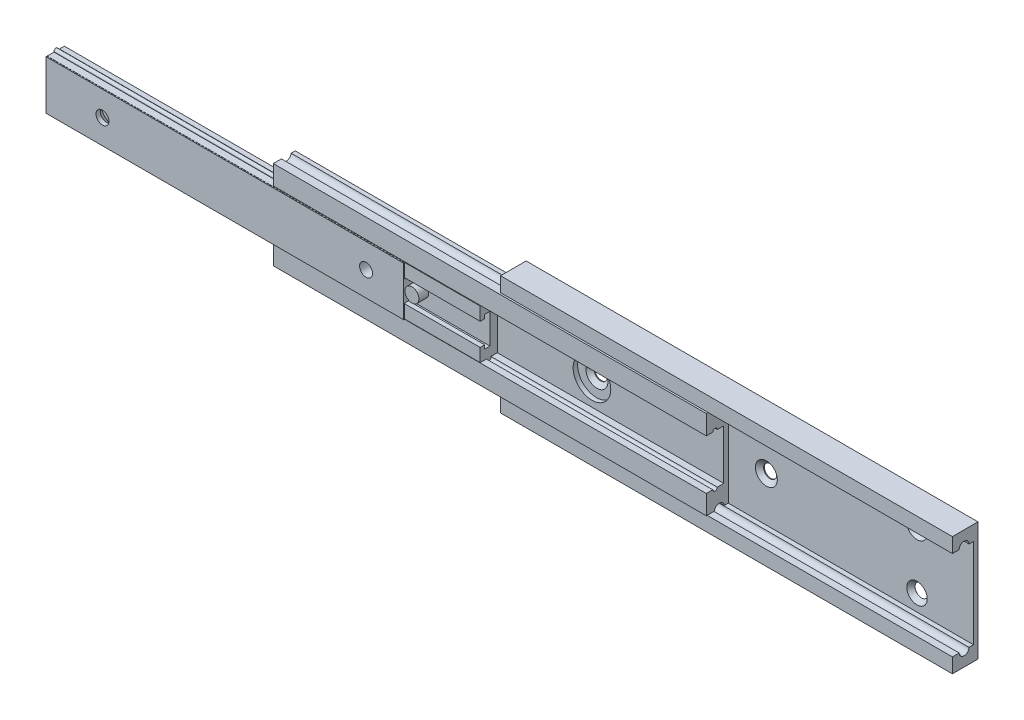
from build123d import *

# Parameters (mm, degrees)
EXTRUDE1_DEPTH        = 152.4
EXTRUDE2_DEPTH        = 146.05
EXTRUDE3_DEPTH        = 146.05
SKETCH9_R             = 2.3749
EXTRUDE4_DEPTH        = 3.302
EXTRUDE5_DEPTH        = 120.65
SKETCH4_R             = 2.1844
CUT_EXTRUDE1_DEPTH    = 1.524
CHAMFER1_SIZE         = 1.27
CHAMFER1_SIZE2        = 1.513527063
CHAMFER1_PART_2_SIZE  = 1.27
CHAMFER1_PART_2_SIZE2 = 1.513527063
CHAMFER1_PART_3_SIZE  = 1.27
CHAMFER1_PART_3_SIZE2 = 1.513527063
SKETCH5_R             = 6.35
CUT_EXTRUDE2_DEPTH    = 1.524
SKETCH6_R             = 2.1844
CUT_EXTRUDE3_DEPTH    = 3.429
CHAMFER2_SIZE         = 1.6637
CHAMFER2_SIZE2        = 1.982720452


with BuildPart() as part:
    # Sketch1 → Extrude1 (new body)
    with BuildSketch(Plane(origin=(0, 0, 0), x_dir=(0, 0, -1), z_dir=(1, 0, 0))):
        with BuildLine():
            Line((-4.318, 20.0421875), (4.318, 20.0421875))
            Line((4.318, 20.0421875), (4.318, -20.0421875))
            Line((4.318, -20.0421875), (-4.318, -20.0421875))
            Line((-4.318, -20.0421875), (-4.318, -15.0891875))
            Line((-4.318, -15.0891875), (-2.032, -15.0891875))
            ThreePointArc((-2.032, -15.0891875), (-0.381, -16.7401875), (1.27, -15.0891875))
            Line((1.27, -15.0891875), (2.794, -15.0891875))
            Line((2.794, -15.0891875), (2.794, 15.0891875))
            Line((2.794, 15.0891875), (1.27, 15.0891875))
            ThreePointArc((1.27, 15.0891875), (-0.381, 16.7401875), (-2.032, 15.0891875))
            Line((-2.032, 15.0891875), (-4.318, 15.0891875))
            Line((-4.318, 15.0891875), (-4.318, 20.0421875))
        make_face()
    extrude(amount=EXTRUDE1_DEPTH)

    # Sketch4 → Cut-Extrude1 (cut)
    with BuildSketch(Plane.XY.offset(-2.794)):
        with Locations((133.35, 9.525)):
            Circle(SKETCH4_R)
        with Locations((133.35, -9.525)):
            Circle(SKETCH4_R)
        with Locations((82.55, 0)):
            Circle(SKETCH4_R)
        with Locations((25.4, 0)):
            Circle(SKETCH4_R)
    extrude(amount=-CUT_EXTRUDE1_DEPTH, mode=Mode.SUBTRACT)

    # Chamfer1
    chamfer1_edges = [part.edges().sort_by_distance(p)[0] for p in [
        (131.1656, 9.525, -2.794),
        (131.1656, -9.525, -2.794),
    ]]
    chamfer1_side = [part.faces().sort_by_distance(p)[0] for p in [
        (75.96932574, 0, -2.794),
    ]]
    chamfer(chamfer1_edges, length=CHAMFER1_SIZE, length2=CHAMFER1_SIZE2, reference=chamfer1_side[0])

    # Chamfer1 part 2
    chamfer1_part_2_edges = [part.edges().sort_by_distance(p)[0] for p in [
        (80.3656, 0, -2.794),
    ]]
    chamfer1_part_2_side = [part.faces().sort_by_distance(p)[0] for p in [
        (80.3656, 0, -3.556),
    ]]
    chamfer(chamfer1_part_2_edges, length=CHAMFER1_PART_2_SIZE, length2=CHAMFER1_PART_2_SIZE2, reference=chamfer1_part_2_side[0])

    # Chamfer1 part 3
    chamfer1_part_3_edges = [part.edges().sort_by_distance(p)[0] for p in [
        (23.2156, 0, -2.794),
    ]]
    chamfer1_part_3_side = [part.faces().sort_by_distance(p)[0] for p in [
        (23.2156, 0, -3.556),
    ]]
    chamfer(chamfer1_part_3_edges, length=CHAMFER1_PART_3_SIZE, length2=CHAMFER1_PART_3_SIZE2, reference=chamfer1_part_3_side[0])


with BuildPart() as body_2:
    # Sketch2 → Extrude2 (new body)
    with BuildSketch(Plane(origin=(-76.2, 0, 0), x_dir=(0, 0, -1), z_dir=(1, 0, 0))):
        with BuildLine():
            Line((-4.7625, 14.9367875), (-2.024951106, 14.9367875))
            ThreePointArc((-2.024951106, 14.9367875), (-0.381, 13.4381875), (1.262951106, 14.9367875))
            Line((1.262951106, 14.9367875), (2.6416, 14.9367875))
            Line((2.6416, 14.9367875), (2.6416, -14.9367875))
            Line((2.6416, -14.9367875), (1.262951106, -14.9367875))
            ThreePointArc((1.262951106, -14.9367875), (-0.381, -13.4381875), (-2.024951106, -14.9367875))
            Line((-2.024951106, -14.9367875), (-4.7625, -14.9367875))
            Line((-4.7625, -14.9367875), (-4.7625, -8.4074))
            Line((-4.7625, -8.4074), (-2.58445, -8.4074))
            ThreePointArc((-2.58445, -8.4074), (-1.82245, -9.1694), (-1.06045, -8.4074))
            Line((-1.06045, -8.4074), (1.1176, -8.4074))
            Line((1.1176, -8.4074), (1.1176, 8.4074))
            Line((1.1176, 8.4074), (-1.06045, 8.4074))
            ThreePointArc((-1.06045, 8.4074), (-1.82245, 9.1694), (-2.58445, 8.4074))
            Line((-2.58445, 8.4074), (-4.7625, 8.4074))
            Line((-4.7625, 8.4074), (-4.7625, 14.9367875))
        make_face()
    extrude(amount=EXTRUDE2_DEPTH)

    # Sketch5 → Cut-Extrude2 (cut)
    with BuildSketch(Plane.XY.offset(-1.1176)):
        with Locations((25.4, 0)):
            Circle(SKETCH5_R)
        with Locations((82.55, 0)):
            Circle(SKETCH5_R)
    extrude(amount=-CUT_EXTRUDE2_DEPTH, mode=Mode.SUBTRACT)


with BuildPart() as body_3:
    # Sketch3 → Extrude3 (new body)
    with BuildSketch(Plane(origin=(-152.4, 0, 0), x_dir=(0, 0, -1), z_dir=(1, 0, 0))):
        with BuildLine():
            Line((-4.826, 8.255), (-2.52095, 8.255))
            Line((-2.52095, 8.255), (-2.52095, 8.4074))
            ThreePointArc((-2.52095, 8.4074), (-1.82245, 9.1059), (-1.12395, 8.4074))
            Line((-1.12395, 8.4074), (-1.12395, 8.255))
            Line((-1.12395, 8.255), (0.9652, 8.255))
            Line((0.9652, 8.255), (0.9652, -8.255))
            Line((0.9652, -8.255), (-1.12395, -8.255))
            Line((-1.12395, -8.255), (-1.12395, -8.4074))
            ThreePointArc((-1.12395, -8.4074), (-1.82245, -9.1059), (-2.52095, -8.4074))
            Line((-2.52095, -8.4074), (-2.52095, -8.255))
            Line((-2.52095, -8.255), (-4.826, -8.255))
            Line((-4.826, -8.255), (-4.826, -3.81))
            Line((-4.826, -3.81), (-3.302, -3.81))
            Line((-3.302, -3.81), (-3.302, -5.08))
            Line((-3.302, -5.08), (-1.524, -5.08))
            Line((-1.524, -5.08), (-1.524, 5.08))
            Line((-1.524, 5.08), (-3.302, 5.08))
            Line((-3.302, 5.08), (-3.302, 3.81))
            Line((-3.302, 3.81), (-4.826, 3.81))
            Line((-4.826, 3.81), (-4.826, 8.255))
        make_face()
    extrude(amount=EXTRUDE3_DEPTH)

    # Sketch9 → Extrude4 (add)
    with BuildSketch(Plane.XY.offset(1.524)):
        with Locations((-29.3751, 0)):
            Circle(SKETCH9_R)
    extrude(amount=EXTRUDE4_DEPTH)


with BuildPart() as body_4:
    # Sketch10 → Extrude5 (new body)
    with BuildSketch(Plane(origin=(-152.4, 0, 0), x_dir=(0, 0, -1), z_dir=(1, 0, 0))):
        Polygon((-4.8768, 8.255), (-4.8768, 3.556), (-3.048, 3.556), (-3.048, 4.826), (-1.778, 4.826), (-1.778, -4.826), (-3.048, -4.826), (-3.048, -3.556), (-4.8768, -3.556), (-4.8768, -8.255), (-5.207, -8.255), (-5.207, 8.255), align=None)
    extrude(amount=EXTRUDE5_DEPTH)

    # Sketch6 → Cut-Extrude3 (cut)
    with BuildSketch(Plane.XY.offset(5.207)):
        with Locations((-133.35, 0)):
            Circle(SKETCH6_R)
        with Locations((-44.45, 0)):
            Circle(SKETCH6_R)
    extrude(amount=-CUT_EXTRUDE3_DEPTH, mode=Mode.SUBTRACT)

    # Chamfer2
    chamfer2_edges = [body_4.edges().sort_by_distance(p)[0] for p in [
        (-135.5344, 0, 1.778),
    ]]
    chamfer2_side = [body_4.faces().sort_by_distance(p)[0] for p in [
        (-92.158901713, 0, 1.778),
    ]]
    chamfer(chamfer2_edges, length=CHAMFER2_SIZE, length2=CHAMFER2_SIZE2, reference=chamfer2_side[0])


solid = Compound([part.part, body_2.part, body_3.part, body_4.part])
